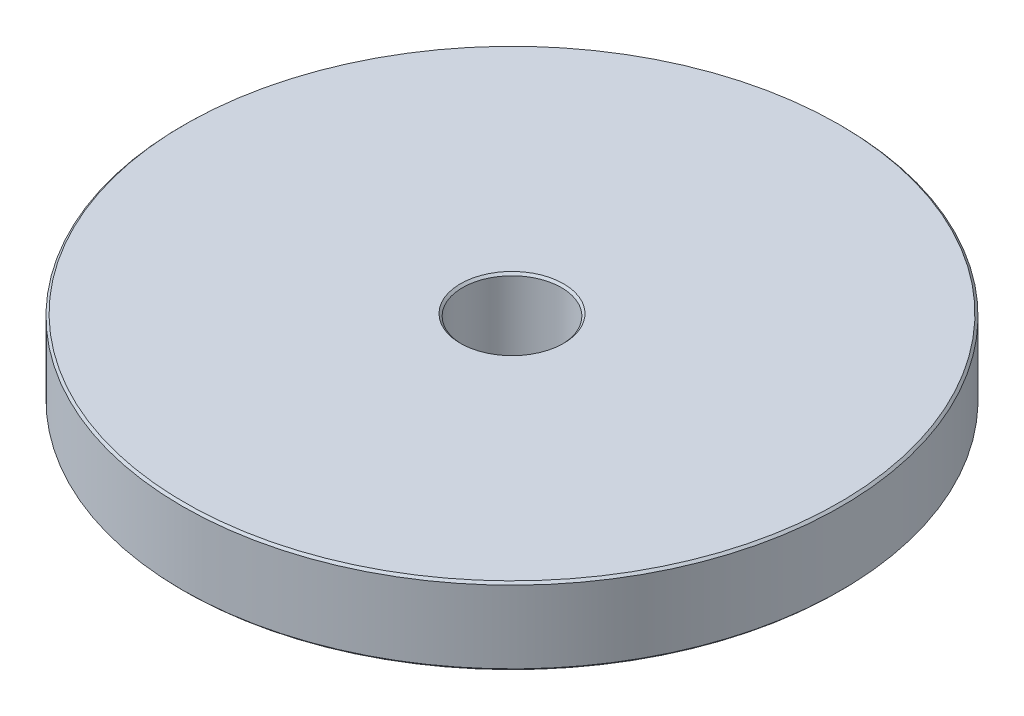
from build123d import *


with BuildPart() as part:
    # Sketch1 → Revolve1 (revolve)
    with BuildSketch(Plane.XY):
        Polygon((4.7, -9.5), (29.8, -9.5), (30, -9.3), (30, -2.7), (29.8, -2.5), (4.7, -2.5), (4.5, -2.7), (4.5, -9.3), align=None)
    revolve(axis=Axis((0, 9.5, 0), (0, -1, 0)))


solid = part.part
